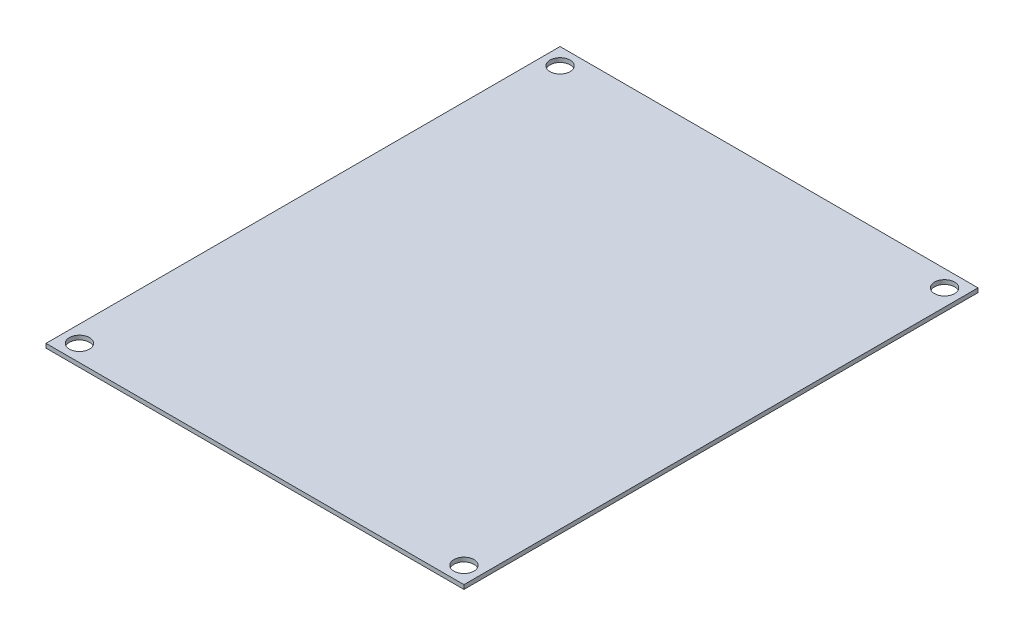
from build123d import *

# Parameters (mm, degrees)
SKETCH1_W            = 100
SKETCH1_H            = 123
BOSS_EXTRUDE1_DEPTH  = 1
M4_CLEARANCE_HOLE1_D = 4.8


with BuildPart() as part:
    # Sketch1 → Boss-Extrude1 (new body)
    with BuildSketch(Plane(origin=(0, 0, 0), x_dir=(1, 0, 0), z_dir=(0, 1, 0))):
        Rectangle(SKETCH1_W, SKETCH1_H)
    extrude(amount=BOSS_EXTRUDE1_DEPTH)

    # M4 Clearance Hole1 (through all)
    with Locations(Plane(origin=(0, 1, 0), x_dir=(1, 0, 0), z_dir=(0, 1, 0))):
        with Locations((-46, -57.5), (-46, 57.5), (46, 57.5), (46, -57.5)):
            Hole(M4_CLEARANCE_HOLE1_D / 2)


solid = part.part
